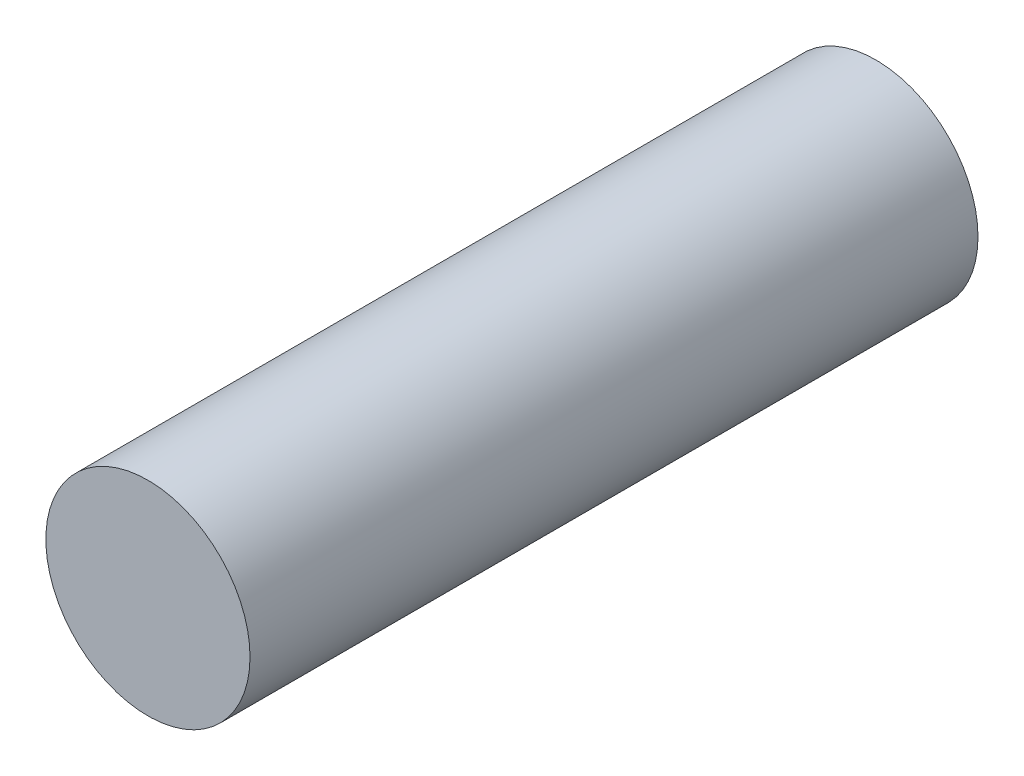
from build123d import *

# Parameters (mm, degrees)
SKETCH1_R           = 18.25625
BOSS_EXTRUDE1_DEPTH = 65.0875


with BuildPart() as part:
    # Sketch1 → Boss-Extrude1 (new body, symmetric)
    with BuildSketch(Plane.XY):
        Circle(SKETCH1_R)
    extrude(amount=BOSS_EXTRUDE1_DEPTH, both=True)


solid = part.part
